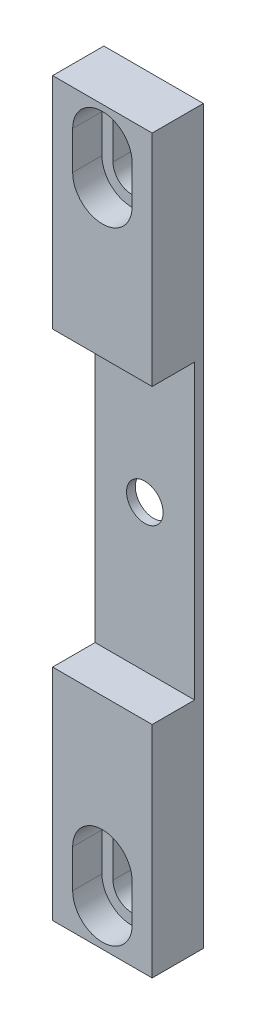
from build123d import *

# Parameters (mm, degrees)
SKETCH1_W                       = 17.272
SKETCH1_H                       = 127
BOSS_EXTRUDE1_DEPTH             = 8.89
F_1_4_0_25_DIAMETER_HOLE1_D     = 6.35
F_1_4_0_25_DIAMETER_HOLE1_DEPTH = 8.89
SKETCH5_W                       = 17.272
SKETCH5_H                       = 50.8
CUT_EXTRUDE1_DEPTH              = 7.366
CUT_EXTRUDE2_DEPTH              = 9.89
CUT_EXTRUDE3_DEPTH              = 5.08


with BuildPart() as part:
    # Sketch1 → Boss-Extrude1 (new body)
    with BuildSketch(Plane.XY):
        Rectangle(SKETCH1_W, SKETCH1_H)
    extrude(amount=BOSS_EXTRUDE1_DEPTH)

    # 1/4 (0.25) Diameter Hole1
    with Locations(Plane.XY.offset(8.89)):
        with Locations((0, 0)):
            Hole(F_1_4_0_25_DIAMETER_HOLE1_D / 2, depth=F_1_4_0_25_DIAMETER_HOLE1_DEPTH)

    # Sketch5 → Cut-Extrude1 (cut)
    with BuildSketch(Plane.XY.offset(8.89)):
        Rectangle(SKETCH5_W, SKETCH5_H)
    extrude(amount=-CUT_EXTRUDE1_DEPTH, mode=Mode.SUBTRACT)

    # Sketch13 → Cut-Extrude2 (cut, through all)
    with BuildSketch(Plane.XY.offset(8.89)):
        with BuildLine():
            Line((3.2385, 57.277), (3.2385, 50.673))
            ThreePointArc((3.2385, 50.673), (0, 47.4345), (-3.2385, 50.673))
            Line((-3.2385, 50.673), (-3.2385, 57.277))
            ThreePointArc((-3.2385, 57.277), (0, 60.5155), (3.2385, 57.277))
        make_face()
        with BuildLine():
            Line((3.2385, -57.277), (3.2385, -50.673))
            ThreePointArc((3.2385, -50.673), (0, -47.4345), (-3.2385, -50.673))
            Line((-3.2385, -50.673), (-3.2385, -57.277))
            ThreePointArc((-3.2385, -57.277), (0, -60.5155), (3.2385, -57.277))
        make_face()
    extrude(amount=-CUT_EXTRUDE2_DEPTH, mode=Mode.SUBTRACT)

    # Sketch14 → Cut-Extrude3 (cut)
    with BuildSketch(Plane.XY.offset(8.89)):
        with BuildLine():
            Line((-5.159375, 50.673), (-5.159375, 57.277))
            ThreePointArc((-5.159375, 57.277), (0, 62.436375), (5.159375, 57.277))
            Line((5.159375, 57.277), (5.159375, 50.673))
            ThreePointArc((5.159375, 50.673), (0, 45.513625), (-5.159375, 50.673))
        make_face()
        with BuildLine():
            Line((5.159375, -50.673), (5.159375, -57.277))
            ThreePointArc((5.159375, -57.277), (0, -62.436375), (-5.159375, -57.277))
            Line((-5.159375, -57.277), (-5.159375, -50.673))
            ThreePointArc((-5.159375, -50.673), (0, -45.513625), (5.159375, -50.673))
        make_face()
    extrude(amount=-CUT_EXTRUDE3_DEPTH, mode=Mode.SUBTRACT)


solid = part.part
